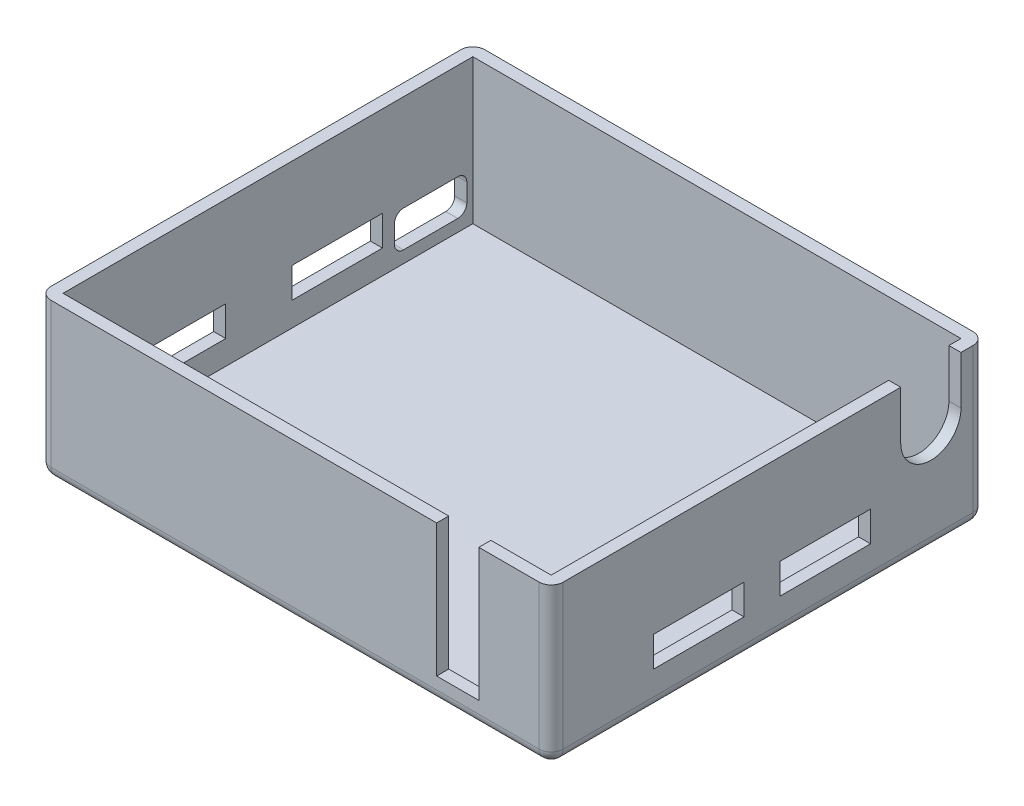
from build123d import *

# Parameters (mm, degrees)
ESQUISSE1_W             = 85
ESQUISSE1_H             = 72
BOSS_EXTRU_1_DEPTH      = 26
COQUE1_T                = -2
ESQUISSE2_R             = 5
ESQUISSE2_W             = 10
ESQUISSE2_H             = 8
ENL_V_MAT_EXTRU_1_DEPTH = 2
ESQUISSE3_W             = 15
ESQUISSE3_H             = 5
ENL_V_MAT_EXTRU_2_DEPTH = 2
ESQUISSE4_W             = 7
ESQUISSE4_H             = 22
ENL_V_MAT_EXTRU_3_DEPTH = 2
ESQUISSE5_W             = 20
ESQUISSE5_H             = 5
ENL_V_MAT_EXTRU_4_DEPTH = 2
ESQUISSE6_W             = 15
ESQUISSE6_H             = 5
ENL_V_MAT_EXTRU_5_DEPTH = 2
ENL_V_MAT_EXTRU_7_DEPTH = 2
CONG_1_R                = 2


with BuildPart() as part:
    # Esquisse1 → Boss.-Extru.1 (new body)
    with BuildSketch(Plane(origin=(0, 0, 0), x_dir=(1, 0, 0), z_dir=(0, 1, 0))):
        Rectangle(ESQUISSE1_W, ESQUISSE1_H)
    extrude(amount=BOSS_EXTRU_1_DEPTH)

    # Coque1
    coque1_openings = [part.faces().sort_by_distance(p)[0] for p in [
        (0, 26, 0),
    ]]
    offset(amount=COQUE1_T, openings=coque1_openings, kind=Kind.INTERSECTION)

    # Esquisse2 → Enlèv. mat.-Extru.1 (cut)
    with BuildSketch(Plane(origin=(42.5, 0, 0), x_dir=(0, 0, -1), z_dir=(1, 0, 0))):
        with Locations((27, 18)):
            Circle(ESQUISSE2_R)
        with Locations((27, 22)):
            Rectangle(ESQUISSE2_W, ESQUISSE2_H)
    extrude(amount=-ENL_V_MAT_EXTRU_1_DEPTH, mode=Mode.SUBTRACT)

    # Esquisse3 → Enlèv. mat.-Extru.2 (cut)
    with BuildSketch(Plane(origin=(42.5, 0, 0), x_dir=(0, 0, -1), z_dir=(1, 0, 0))):
        with Locations((9.5, 8.5)):
            Rectangle(ESQUISSE3_W, ESQUISSE3_H)
        with Locations((-11.5, 8.5)):
            Rectangle(ESQUISSE3_W, ESQUISSE3_H)
    extrude(amount=-ENL_V_MAT_EXTRU_2_DEPTH, mode=Mode.SUBTRACT)

    # Esquisse4 → Enlèv. mat.-Extru.3 (cut)
    with BuildSketch(Plane.XY.offset(36)):
        with Locations((27, 15)):
            Rectangle(ESQUISSE4_W, ESQUISSE4_H)
    extrude(amount=-ENL_V_MAT_EXTRU_3_DEPTH, mode=Mode.SUBTRACT)

    # Esquisse5 → Enlèv. mat.-Extru.4 (cut)
    with BuildSketch(Plane.ZY.offset(42.5)):
        with Locations((17, 8.5)):
            Rectangle(ESQUISSE5_W, ESQUISSE5_H)
    extrude(amount=-ENL_V_MAT_EXTRU_4_DEPTH, mode=Mode.SUBTRACT)

    # Esquisse6 → Enlèv. mat.-Extru.5 (cut)
    with BuildSketch(Plane.ZY.offset(42.5)):
        with Locations((-11.5, 8.5)):
            Rectangle(ESQUISSE6_W, ESQUISSE6_H)
    extrude(amount=-ENL_V_MAT_EXTRU_5_DEPTH, mode=Mode.SUBTRACT)

    # Esquisse8 → Enlèv. mat.-Extru.7 (cut)
    with BuildSketch(Plane.ZY.offset(42.5)):
        with BuildLine():
            Line((-31.5, 10), (-22.5, 10))
            ThreePointArc((-22.5, 10), (-21.439339828, 9.560660172), (-21, 8.5))
            Line((-21, 8.5), (-21, 5.5))
            ThreePointArc((-21, 5.5), (-21.439339828, 4.439339828), (-22.5, 4))
            Line((-22.5, 4), (-31.5, 4))
            ThreePointArc((-31.5, 4), (-32.560660172, 4.439339828), (-33, 5.5))
            Line((-33, 5.5), (-33, 8.5))
            ThreePointArc((-33, 8.5), (-32.560660172, 9.560660172), (-31.5, 10))
        make_face()
    extrude(amount=-ENL_V_MAT_EXTRU_7_DEPTH, mode=Mode.SUBTRACT)

    # Congé1
    cong_1_edges = [part.edges().sort_by_distance(p)[0] for p in [
        (0, 0, -36),
        (42.5, 0, 0),
        (0, 0, 36),
        (-42.5, 0, 0),
        (-42.5, 13, -36),
        (42.5, 13, -36),
        (42.5, 13, 36),
        (-42.5, 13, 36),
    ]]
    fillet(cong_1_edges, radius=CONG_1_R)


solid = part.part
